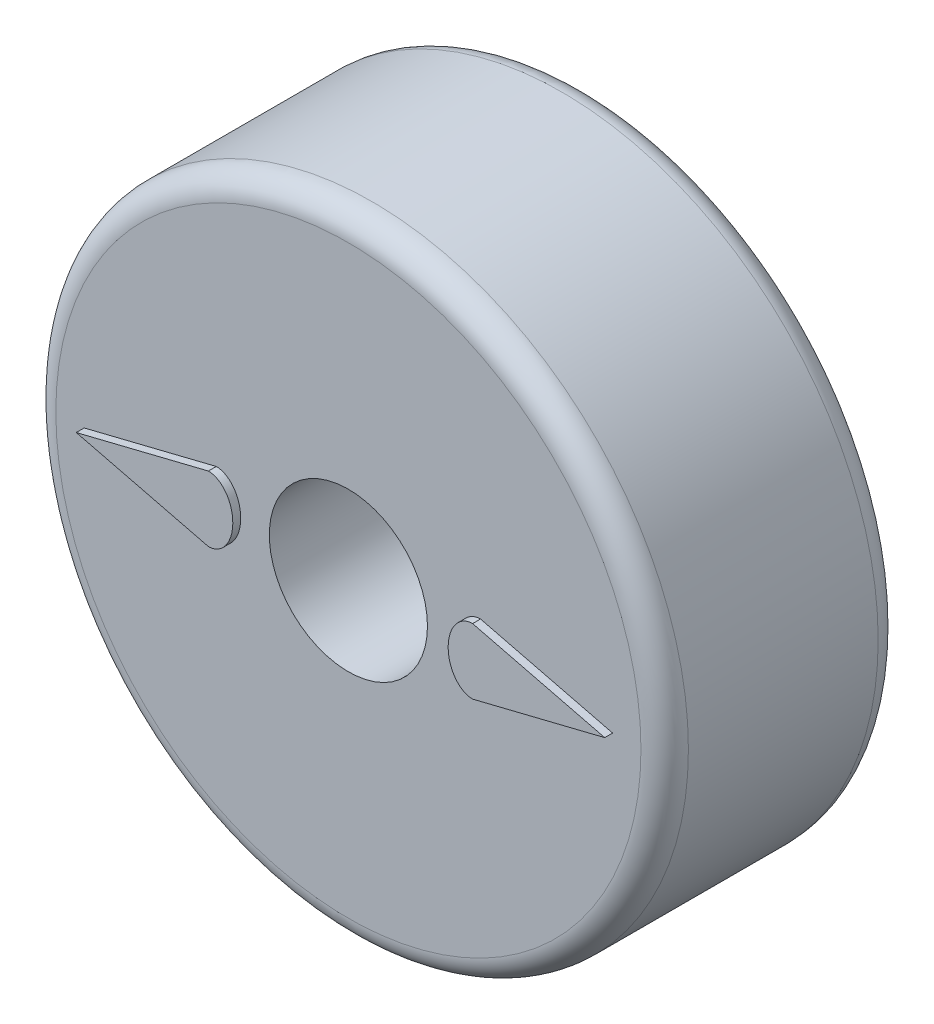
from build123d import *

# Parameters (mm, degrees)
SKETCH1_R           = 101.6
SKETCH1_R_2         = 25.4
BOSS_EXTRUDE1_DEPTH = 76.2
FILLET1_R           = 7.62
BOSS_EXTRUDE2_DEPTH = 2.54


with BuildPart() as part:
    # Sketch1 → Boss-Extrude1 (new body)
    with BuildSketch(Plane.XY):
        Circle(SKETCH1_R)
        Circle(SKETCH1_R_2, mode=Mode.SUBTRACT)
    extrude(amount=BOSS_EXTRUDE1_DEPTH)

    # Fillet1
    fillet1_edges = [part.edges().sort_by_distance(p)[0] for p in [
        (-101.6, 0, 0),
        (-101.6, 0, 76.2),
    ]]
    fillet(fillet1_edges, radius=FILLET1_R)

    # Sketch2 → Boss-Extrude2 (add)
    with BuildSketch(Plane.XY.offset(76.2)):
        with BuildLine():
            add(Edge.make_bspline(
                [(42.436322164, 10.50404014), (34.587368685, 10.50404014), (34.587368685, 0)],
                knots=[0, 0, 0, 1.570796327, 1.570796327, 1.570796327], degree=2, weights=[1, 0.707106781, 1]))
            Line((34.587368685, 0), (84.872644329, 0))
            Line((84.872644329, 0), (42.436322164, 10.50404014))
        make_face()
        with BuildLine():
            Line((84.872644329, 0), (34.587368685, 0))
            add(Edge.make_bspline(
                [(34.587368685, 0), (34.587368685, -10.50404014), (42.436322164, -10.50404014)],
                knots=[1.570796327, 1.570796327, 1.570796327, 3.141592654, 3.141592654, 3.141592654], degree=2, weights=[1, 0.707106781, 1]))
            Line((42.436322164, -10.50404014), (84.872644329, 0))
        make_face()
    boss_extrude2 = extrude(amount=BOSS_EXTRUDE2_DEPTH)

    # Mirror1: Boss-Extrude2 across plane
    add(boss_extrude2.mirror(Plane(origin=(0, 0, 0), x_dir=(0, 0, 1), z_dir=(1, 0, 0))))


solid = part.part
